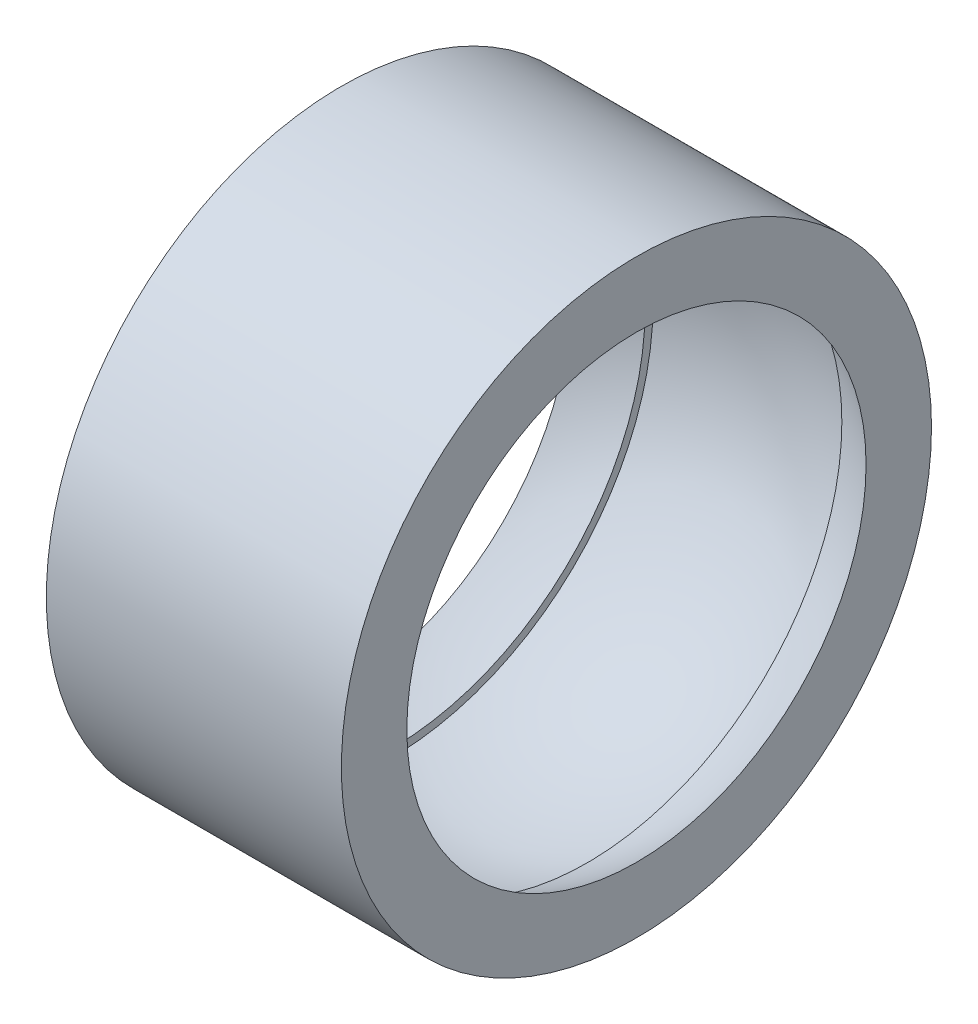
from build123d import *


with BuildPart() as part:
    # Sketch1 → Revolve1 (revolve)
    with BuildSketch(Plane.XY):
        with BuildLine():
            Line((6, 12), (-6, 12))
            Line((-6, 12), (-6, 9.33862945))
            ThreePointArc((-6, 9.33862945), (-5.025719768, 9.897077388), (-4, 10.35422619))
            Line((-4, 10.35422619), (-4, 10.675204916))
            ThreePointArc((-4, 10.675204916), (0, 11.4), (4, 10.675204916))
            Line((4, 10.675204916), (4, 10.35422619))
            ThreePointArc((4, 10.35422619), (5.025719768, 9.897077388), (6, 9.33862945))
            Line((6, 9.33862945), (6, 12))
        make_face()
    revolve(axis=Axis((48.348883339, 0, 0), (-1, 0, 0)))


solid = part.part
